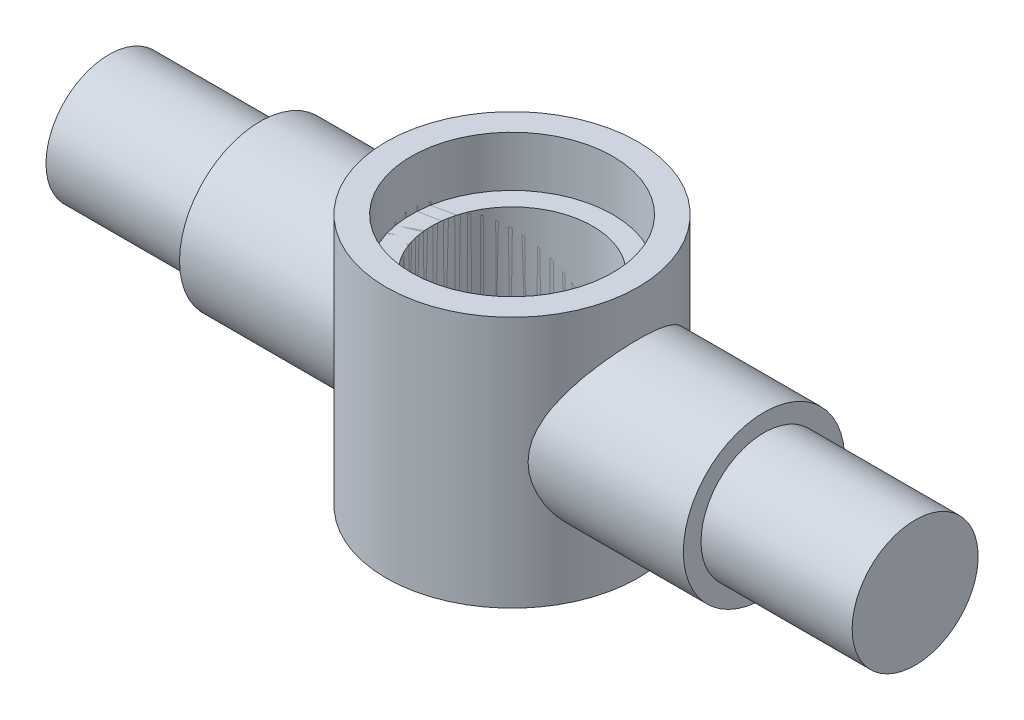
from build123d import *

# Parameters (mm, degrees)
SKETCH2_R               = 25
SKETCH2_R_2             = 16
BOSS_EXTRUDE2_DEPTH     = 25
CUT_EXTRUDE1_DEPTH      = 88.464278423
CUT_EXTRUDE1_DEPTH_BACK = 88.464278423
SKETCH2_3_R             = 16
SKETCH3_R               = 20
CUT_EXTRUDE2_DEPTH      = 10


with BuildPart() as part:
    # Sketch1 → Revolve2 (revolve)
    with BuildSketch(Plane(origin=(0, 0, 0), x_dir=(1, 0, 0), z_dir=(0, 1, 0))):
        Polygon((-80, -12.5), (-50, -12.5), (-50, -16), (50, -16), (50, -12.5), (80, -12.5), (80, 0), (79.691777251, 0), (-80, 0), align=None)
    revolve(axis=Axis((50, 0, 0), (1, 0, 0)))

    # Sketch2_3 → Cut-Extrude1 (cut, two sides: drawn at the far end of the back side and taken through both)
    with BuildSketch(Plane(origin=(0, 0, 0), x_dir=(1, 0, 0), z_dir=(0, 1, 0)).offset(-CUT_EXTRUDE1_DEPTH_BACK)):
        Circle(SKETCH2_3_R)
    extrude(amount=CUT_EXTRUDE1_DEPTH + CUT_EXTRUDE1_DEPTH_BACK, mode=Mode.SUBTRACT)


with BuildPart() as body_2:
    # Sketch2 → Boss-Extrude2 (new, symmetric)
    with BuildSketch(Plane(origin=(0, 0, 0), x_dir=(1, 0, 0), z_dir=(0, 1, 0))):
        Circle(SKETCH2_R)
        Circle(SKETCH2_R_2, mode=Mode.SUBTRACT)
    extrude(amount=BOSS_EXTRUDE2_DEPTH, both=True)


with BuildPart() as cut_extrude1_piece_1:
    # of the separate pieces the step leaves, piece 1, a body of its own (cut_extrude1_pieces)
    add(part.part.solids().sort_by_distance((-80, 0, 12.5))[0])


with BuildPart() as cut_extrude1_piece_2:
    # of the separate pieces the step leaves, piece 2, a body of its own (cut_extrude1_pieces)
    add(part.part.solids().sort_by_distance((16, 16, 0))[0])


with BuildPart() as cut_extrude2_tool:
    # Sketch3 → Cut-Extrude2 (new body)
    with BuildSketch(Plane(origin=(0, 25, 0), x_dir=(1, 0, 0), z_dir=(0, 1, 0))):
        Circle(SKETCH3_R)
    extrude(amount=-CUT_EXTRUDE2_DEPTH)


with BuildPart() as body_2_1:
    add(body_2.part)

    # Cut-Extrude2: cut by cut_extrude2_tool
    add(cut_extrude2_tool.part, mode=Mode.SUBTRACT)


with BuildPart() as cut_extrude1_piece_1_1:
    add(cut_extrude1_piece_1.part)

    # Cut-Extrude2: cut by cut_extrude2_tool
    add(cut_extrude2_tool.part, mode=Mode.SUBTRACT)


with BuildPart() as cut_extrude1_piece_2_1:
    add(cut_extrude1_piece_2.part)

    # Cut-Extrude2: cut by cut_extrude2_tool
    add(cut_extrude2_tool.part, mode=Mode.SUBTRACT)


solid = Compound([body_2_1.part, cut_extrude1_piece_1_1.part, cut_extrude1_piece_2_1.part])
